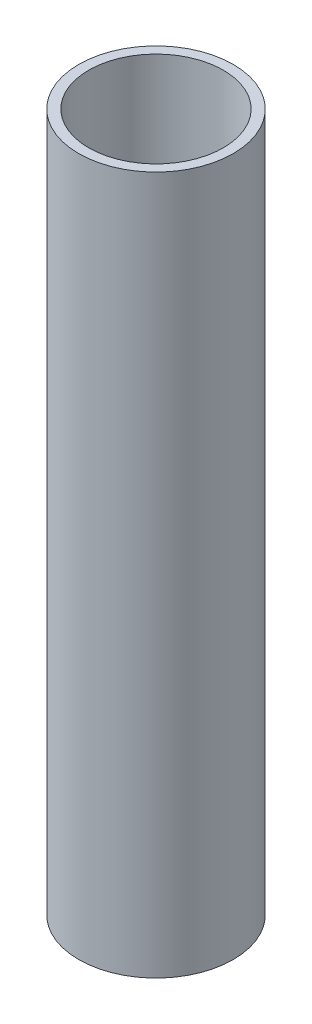
from build123d import *

# Parameters (mm, degrees)
SKETCH1_R           = 15.5
SKETCH1_R_2         = 13.5
BOSS_EXTRUDE1_DEPTH = 140


with BuildPart() as part:
    # Sketch1 → Boss-Extrude1 (new body)
    with BuildSketch(Plane(origin=(0, 0, 0), x_dir=(1, 0, 0), z_dir=(0, 1, 0))):
        Circle(SKETCH1_R)
        Circle(SKETCH1_R_2, mode=Mode.SUBTRACT)
    extrude(amount=BOSS_EXTRUDE1_DEPTH)


solid = part.part
